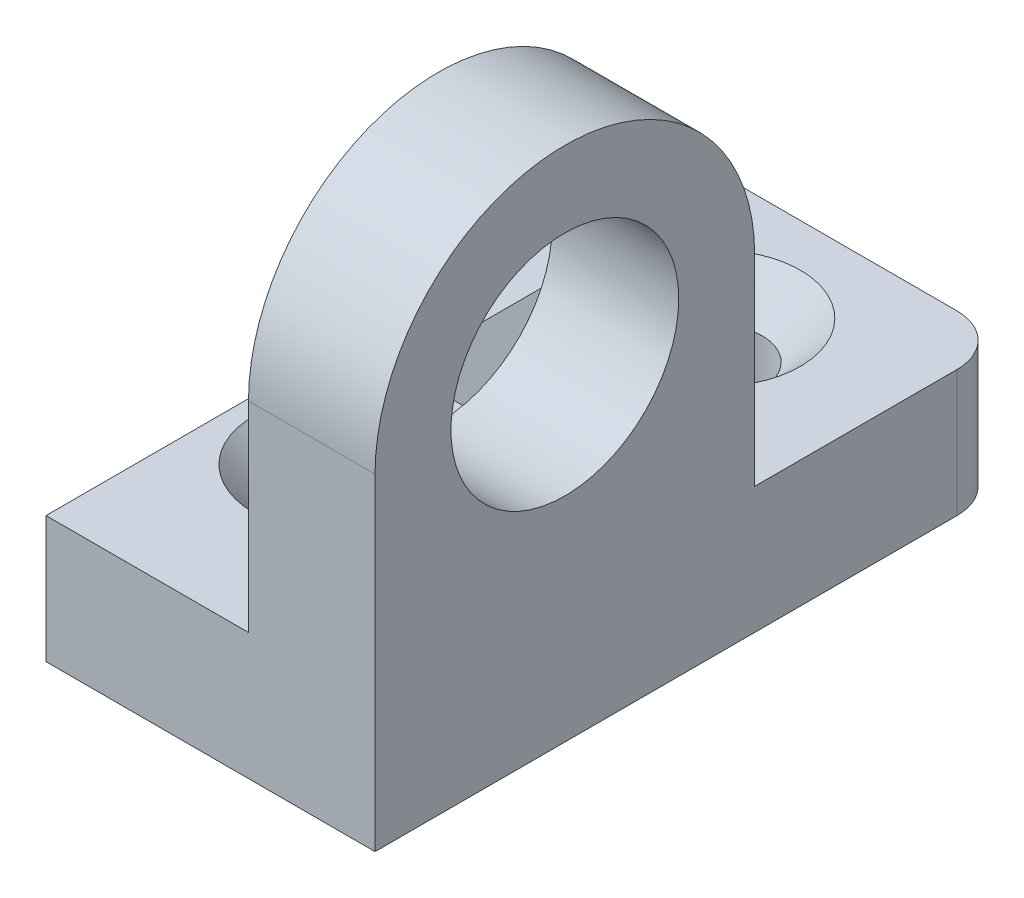
from build123d import *

# Parameters (mm, degrees)
SKETCH_1_R                = 4.5
EXTRUDE_1_DEPTH           = 5
SKETCH_2_W                = 13
SKETCH_2_H                = 25
EXTRUDE_2_DEPTH           = 5
RIB_1_REACH               = 23.352
SKETCH_3_WALL_W           = 53.190153214
SKETCH_3_WALL_H           = 3
HOLE_WIZARD_1_D           = 3.6
HOLE_WIZARD_1_CSINK_D     = 6.6
HOLE_WIZARD_1_CSINK_ANGLE = 90
FILLET_1_R                = 2


with BuildPart() as part:
    # 草图1 → 凸台-拉伸1 (new body)
    with BuildSketch(Plane(origin=(0, 0, 0), x_dir=(0, 0, -1), z_dir=(1, 0, 0))):
        with BuildLine():
            Line((7.5, 0), (7.5, -12.920004632))
            Line((7.5, -12.920004632), (-7.5, -12.920004632))
            Line((-7.5, -12.920004632), (-7.5, 0))
            ThreePointArc((-7.5, 0), (0, 7.5), (7.5, 0))
        make_face()
        Circle(SKETCH_1_R, mode=Mode.SUBTRACT)
    extrude(amount=EXTRUDE_1_DEPTH)

    # 草图2 → 凸台-拉伸2 (add)
    with BuildSketch(Plane.XZ.offset(12.920004632)):
        with Locations((-1.5, -5)):
            Rectangle(SKETCH_2_W, SKETCH_2_H)
    extrude(amount=-EXTRUDE_2_DEPTH)

    # 草图3 wall → 筋1 (add, up to next)
    with BuildSketch(Plane(origin=(-3, -4.920004632, -7.5), x_dir=(-0.707106781187, -0.707106781187, 0), z_dir=(-0.707106781187, 0.707106781187, 0)), mode=Mode.PRIVATE) as rib_1_sk1:
        with Locations((0, 1.5)):
            Rectangle(SKETCH_3_WALL_W, SKETCH_3_WALL_H)
    rib_1_tool1 = extrude(rib_1_sk1.sketch, amount=-RIB_1_REACH, mode=Mode.PRIVATE) - part.part
    add(rib_1_tool1.solids().sort_by_distance((-3, -4.920004632, -7.5))[0])

    # 打孔尺寸(%根据十字)槽半沉头木螺钉的类型1 (through all)
    with Locations(Plane(origin=(0, -7.920004632, 0), x_dir=(1, 0, 0), z_dir=(0, 1, 0))):
        with Locations((-1.5, 12.5), (-4, 0)):
            CounterSinkHole(HOLE_WIZARD_1_D / 2, HOLE_WIZARD_1_CSINK_D / 2, counter_sink_angle=HOLE_WIZARD_1_CSINK_ANGLE)

    # 圆角1
    fillet_1_edges = [part.edges().sort_by_distance(p)[0] for p in [
        (5, -10.420004632, -17.5),
    ]]
    fillet(fillet_1_edges, radius=FILLET_1_R)


solid = part.part
